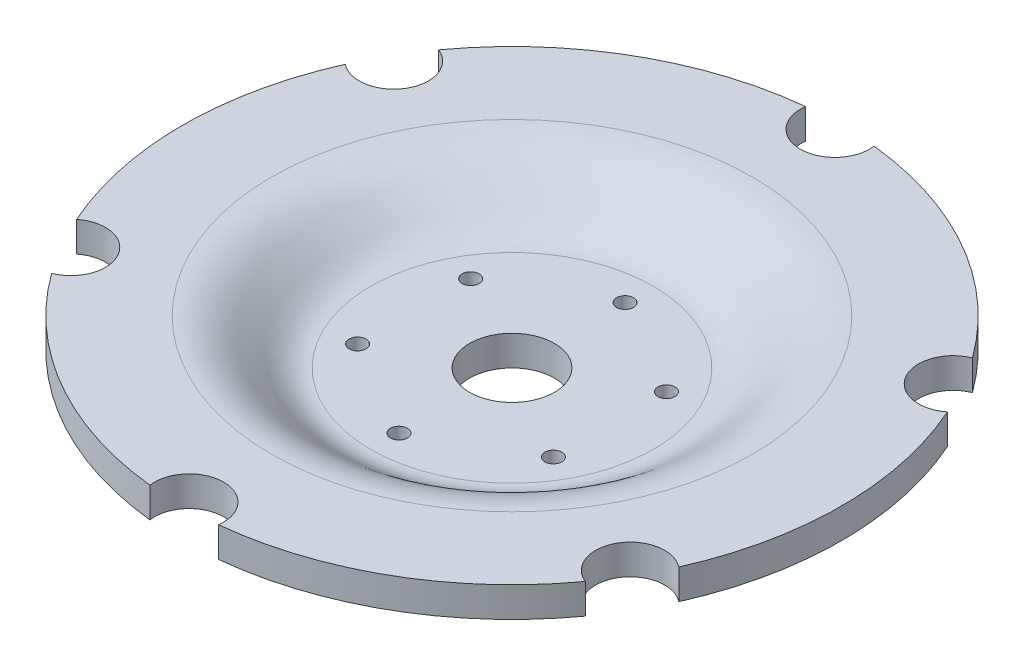
from build123d import *

# Parameters (mm, degrees)
F_23_0_23_DIAMETER_HOLE2_D = 23
M5_CLEARANCE_HOLE1_D       = 5.64
M5_CLEARANCE_HOLE1_DEPTH   = 10
M25_CLEARANCE_HOLE1_D      = 28.2


with BuildPart() as part:
    # Sketch1 → Revolve1 (revolve)
    with BuildSketch(Plane(origin=(0, 0, 0), x_dir=(-1, 0, 0), z_dir=(0, 0, -1))):
        with BuildLine():
            Line((0, -21.28), (-47, -21.28))
            add(Edge.make_bspline(
                [(-47, -21.28), (-48.103397798, -21.28), (-50.355208609, -21.119817001), (-53.414331373, -20.453461244), (-56.243773206, -19.439198841), (-59.638625381, -17.760520516), (-63.24918477, -15.301778213), (-66.920694033, -12.332831089), (-70.220914899, -9.726996026), (-72.788397394, -8.094435047), (-74.823949114, -7.162885506), (-76.366758302, -6.651929985), (-77.75784267, -6.37664197), (-78.927463, -6.261355146), (-79.581421905, -6.24), (-79.9, -6.24)],
                knots=[0, 0, 0, 0, 0.0625, 0.125, 0.1875, 0.25, 0.375, 0.5, 0.625, 0.75, 0.8125, 0.875, 0.9375, 0.96875, 1, 1, 1, 1], degree=3))
            Line((-79.9, -6.24), (-109.626011544, -6.24))
            Line((-109.626011544, -6.24), (-109.626011544, 3.76))
            Line((-109.626011544, 3.76), (-79.9, 3.76))
            add(Edge.make_bspline(
                [(-47, -11.28), (-47.323760623, -11.28), (-47.9824274, -11.256801184), (-49.205881481, -11.125337538), (-50.652473039, -10.813460463), (-52.303634488, -10.223599604), (-54.465904258, -9.163050099), (-57.16913982, -7.350711887), (-60.559773273, -4.61985368), (-64.271682561, -1.670850737), (-67.847161888, 0.63981733), (-71.12599799, 2.151104958), (-73.810430606, 3.042514571), (-76.243250574, 3.525131309), (-78.291888688, 3.725497683), (-79.368008784, 3.76), (-79.9, 3.76)],
                knots=[0, 0, 0, 0, 0.03125, 0.0625, 0.125, 0.1875, 0.25, 0.375, 0.5, 0.625, 0.75, 0.8125, 0.875, 0.9375, 0.96875, 1, 1, 1, 1], degree=3))
            Line((-47, -11.28), (0, -11.28))
            Line((0, -11.28), (0, -21.28))
        make_face()
    revolve(axis=Axis((0, -15.043324423, 0), (0, 1, 0)))

    # Ø23.0 (23) Diameter Hole2 (through all)
    with Locations(Plane(origin=(0, 3.76, 0), x_dir=(1, 0, 0), z_dir=(0, 1, 0))):
        with Locations((-92.997954647, 53.69239415), (92.997954647, -53.69239415), (92.997954647, 53.69239415), (0, 107.3847883), (-92.997954647, -53.69239415), (0, -107.3847883)):
            Hole(F_23_0_23_DIAMETER_HOLE2_D / 2)

    # M5 Clearance Hole1
    with Locations(Plane(origin=(0, -11.28, 0), x_dir=(1, 0, 0), z_dir=(0, 1, 0))):
        with Locations((-32.562555182, 18.8), (0, 37.6), (32.562555182, 18.8), (32.562555182, -18.8), (0, -37.6), (-32.562555182, -18.8)):
            Hole(M5_CLEARANCE_HOLE1_D / 2, depth=M5_CLEARANCE_HOLE1_DEPTH)

    # M25 Clearance Hole1 (through all)
    with Locations(Plane(origin=(0, -11.28, 0), x_dir=(1, 0, 0), z_dir=(0, 1, 0))):
        with Locations((0, 0)):
            Hole(M25_CLEARANCE_HOLE1_D / 2)


solid = part.part
